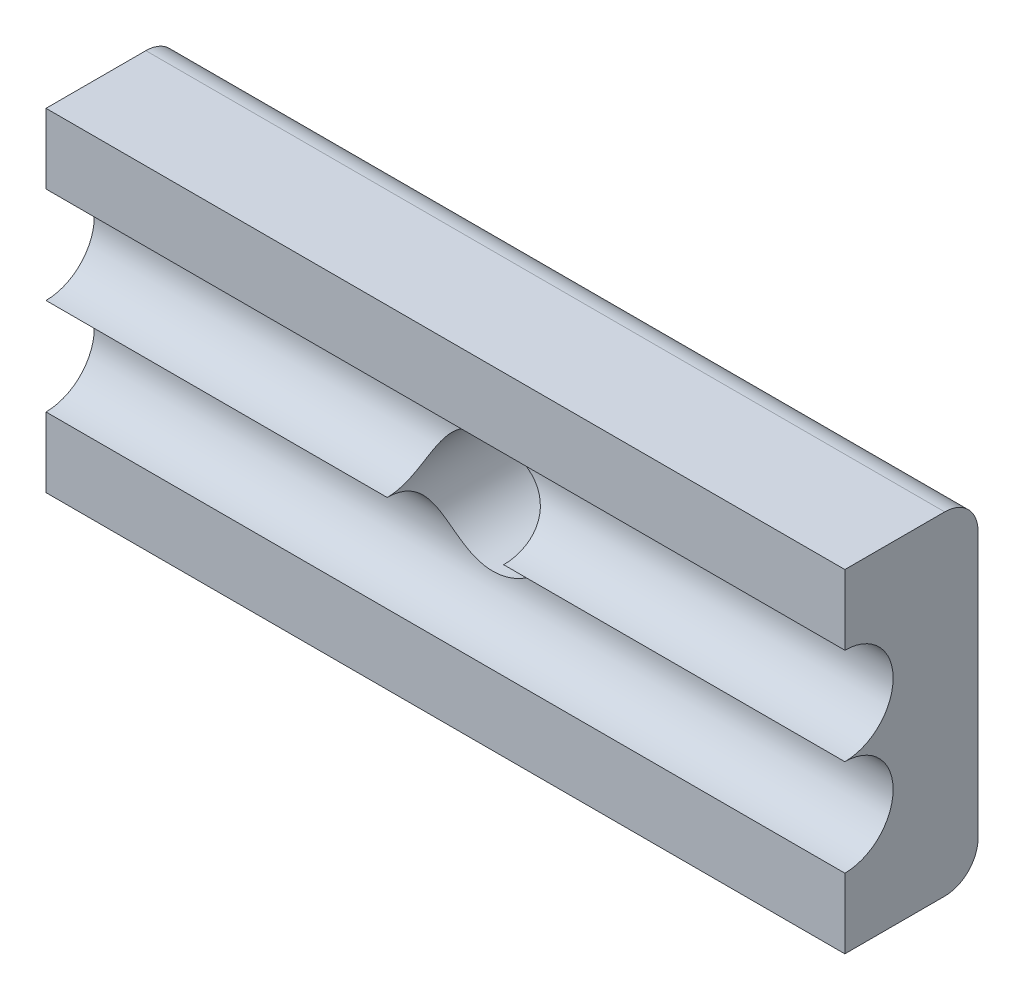
from build123d import *

# Parameters (mm, degrees)
SKETCH2_W           = 24
SKETCH2_H           = 10
BOSS_EXTRUDE1_DEPTH = 4
SKETCH3_R           = 1.75
CUT_EXTRUDE1_DEPTH  = 5
FILLET1_R           = 1
CUT_EXTRUDE2_DEPTH  = 30


with BuildPart() as part:
    # Sketch2 → Boss-Extrude1 (new body)
    with BuildSketch(Plane.XY):
        with Locations((6.957345972, -1)):
            Rectangle(SKETCH2_W, SKETCH2_H)
    extrude(amount=BOSS_EXTRUDE1_DEPTH)

    # Sketch3 → Cut-Extrude1 (cut)
    with BuildSketch(Plane.XY.offset(4)):
        with Locations((6.957345972, -1)):
            Circle(SKETCH3_R)
    extrude(amount=-CUT_EXTRUDE1_DEPTH, mode=Mode.SUBTRACT)

    # Fillet1
    fillet1_edges = [part.edges().sort_by_distance(p)[0] for p in [
        (6.957345972, 4, 0),
        (6.957345972, -6, 0),
    ]]
    fillet(fillet1_edges, radius=FILLET1_R)

    # Sketch4 → Cut-Extrude2 (cut)
    with BuildSketch(Plane.ZY.offset(5.042654028)):
        with BuildLine():
            ThreePointArc((4, -3.9), (5.025304833, -3.475304833), (5.45, -2.45))
            ThreePointArc((5.45, -2.45), (5.025304832, -1.424695167), (3.999999998, -1))
            Line((4, -1), (4, -3.9))
        make_face()
        with BuildLine():
            Line((4, -3.9), (4, -1))
            ThreePointArc((3.999999998, -1), (2.55, -2.450000001), (4, -3.9))
        make_face()
        with BuildLine():
            ThreePointArc((4, 1.9), (2.55, 0.450000001), (3.999999998, -1))
            Line((4, -1), (4, 1.9))
        make_face()
        with BuildLine():
            Line((4, 1.9), (4, -1))
            ThreePointArc((3.999999998, -1), (5.025304832, -0.575304833), (5.45, 0.45))
            ThreePointArc((5.45, 0.45), (5.025304833, 1.475304833), (4, 1.9))
        make_face()
    extrude(amount=-CUT_EXTRUDE2_DEPTH, mode=Mode.SUBTRACT)


solid = part.part
